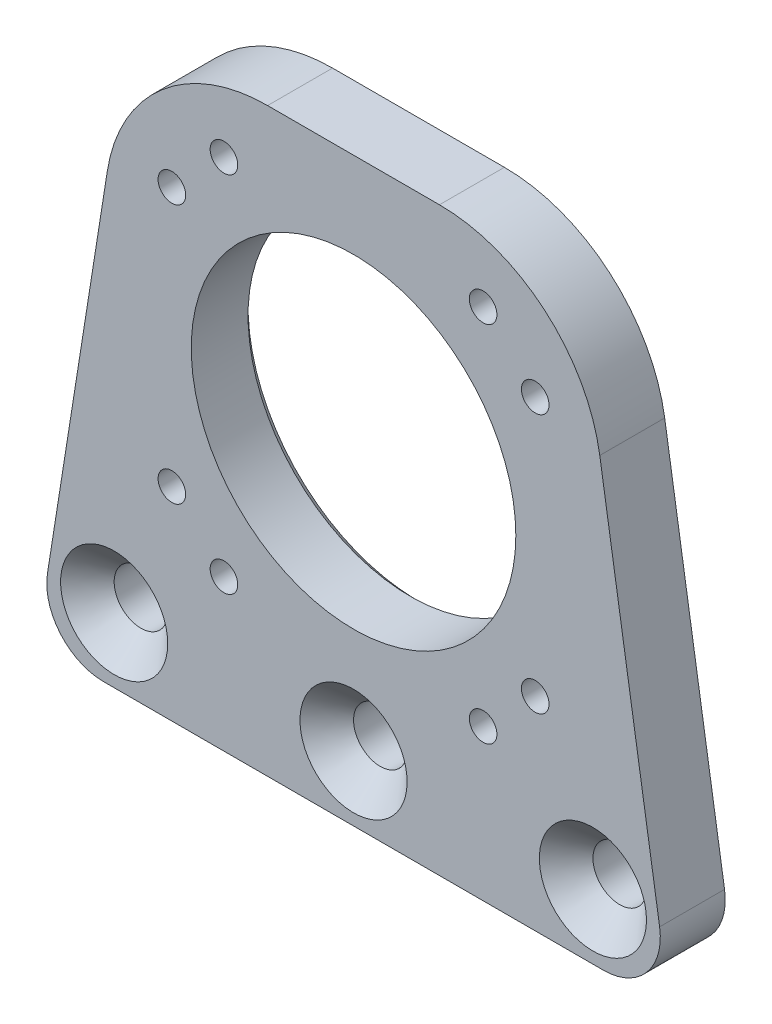
from build123d import *

# Parameters (mm, degrees)
SKETCH_1_R                = 20
SKETCH_1_R_2              = 1.5
SKETCH_1_R_3              = 3
EXTRUDE_1_DEPTH           = 8
HOLE_WIZARD_1_D           = 3.4
HOLE_WIZARD_1_DEPTH       = 8.1
HOLE_WIZARD_1_CSINK_D     = 6.6
HOLE_WIZARD_1_CSINK_ANGLE = 90
HOLE_WIZARD_1_TIP         = 1.021463052
HOLE_WIZARD_2_D           = 6.6
HOLE_WIZARD_2_DEPTH       = 8.1
HOLE_WIZARD_2_CSINK_D     = 13.2
HOLE_WIZARD_2_CSINK_ANGLE = 90
HOLE_WIZARD_2_TIP         = 1.982840043
CHAMFER_1_SIZE            = 1


with BuildPart() as part:
    # 草图1 → 凸台-拉伸1 (new body)
    with BuildSketch(Plane.XY):
        with BuildLine():
            Line((-37.719505087, 14.893838596), (-30.34379321, 61.5147356))
            ThreePointArc((-30.34379321, 61.5147356), (-23.579766095, 73.596472023), (-10.589482469, 78.389482469))
            Line((-10.589482469, 78.389482469), (10.589482469, 78.389482469))
            ThreePointArc((10.589482469, 78.389482469), (23.579766095, 73.596472023), (30.34379321, 61.5147356))
            Line((30.34379321, 61.5147356), (37.719505087, 14.893838596))
            ThreePointArc((37.719505087, 14.893838596), (36.127942671, 9.253400731), (30.805496327, 6.8))
            Line((30.805496327, 6.8), (-30.805496327, 6.8))
            ThreePointArc((-30.805496327, 6.8), (-36.127942671, 9.253400731), (-37.719505087, 14.893838596))
        make_face()
        with Locations((0, 47.8)):
            Circle(SKETCH_1_R, mode=Mode.SUBTRACT)
        with Locations((-15.969331282, 70.188176755)):
            Circle(SKETCH_1_R_2, mode=Mode.SUBTRACT)
        with Locations((-22.388176755, 63.769331282)):
            Circle(SKETCH_1_R_2, mode=Mode.SUBTRACT)
        with Locations((-22.388176755, 31.830668718)):
            Circle(SKETCH_1_R_2, mode=Mode.SUBTRACT)
        with Locations((-15.969331282, 25.411823245)):
            Circle(SKETCH_1_R_2, mode=Mode.SUBTRACT)
        with Locations((15.969331282, 25.411823245)):
            Circle(SKETCH_1_R_2, mode=Mode.SUBTRACT)
        with Locations((22.388176755, 31.830668718)):
            Circle(SKETCH_1_R_2, mode=Mode.SUBTRACT)
        with Locations((22.388176755, 63.769331282)):
            Circle(SKETCH_1_R_2, mode=Mode.SUBTRACT)
        with Locations((15.969331282, 70.188176755)):
            Circle(SKETCH_1_R_2, mode=Mode.SUBTRACT)
        with Locations((-29.5, 14.8)):
            Circle(SKETCH_1_R_3, mode=Mode.SUBTRACT)
        with Locations((0, 14.8)):
            Circle(SKETCH_1_R_3, mode=Mode.SUBTRACT)
        with Locations((29.5, 14.8)):
            Circle(SKETCH_1_R_3, mode=Mode.SUBTRACT)
    extrude(amount=EXTRUDE_1_DEPTH)

    # 打孔尺寸(%根据十字)槽沉头木螺钉的类型1
    with Locations(Plane(origin=(0, 0, 0), x_dir=(-1, 0, 0), z_dir=(0, 0, -1))):
        with Locations((-22.388176755, 63.769331282), (-15.969331282, 70.188176755), (15.969331282, 70.188176755), (22.388176755, 63.769331282), (-22.388176755, 31.830668718), (-15.969331282, 25.411823245), (15.969331282, 25.411823245), (22.388176755, 31.830668718)):
            CounterSinkHole(HOLE_WIZARD_1_D / 2, HOLE_WIZARD_1_CSINK_D / 2, depth=HOLE_WIZARD_1_DEPTH, counter_sink_angle=HOLE_WIZARD_1_CSINK_ANGLE)
            with Locations((0, 0, -(HOLE_WIZARD_1_DEPTH + HOLE_WIZARD_1_TIP / 2))):  # 118° drill point
                Cone(0, HOLE_WIZARD_1_D / 2, HOLE_WIZARD_1_TIP, mode=Mode.SUBTRACT)

    # 打孔尺寸(%根据十字)槽沉头木螺钉的类型2
    with Locations(Plane.XY.offset(8)):
        with Locations((29.5, 14.8), (0, 14.8), (-29.5, 14.8)):
            CounterSinkHole(HOLE_WIZARD_2_D / 2, HOLE_WIZARD_2_CSINK_D / 2, depth=HOLE_WIZARD_2_DEPTH, counter_sink_angle=HOLE_WIZARD_2_CSINK_ANGLE)
            with Locations((0, 0, -(HOLE_WIZARD_2_DEPTH + HOLE_WIZARD_2_TIP / 2))):  # 118° drill point
                Cone(0, HOLE_WIZARD_2_D / 2, HOLE_WIZARD_2_TIP, mode=Mode.SUBTRACT)

    # 倒角1
    chamfer_1_edges = [part.edges().sort_by_distance(p)[0] for p in [
        (-20, 47.8, 0),
    ]]
    chamfer(chamfer_1_edges, length=CHAMFER_1_SIZE)


solid = part.part
